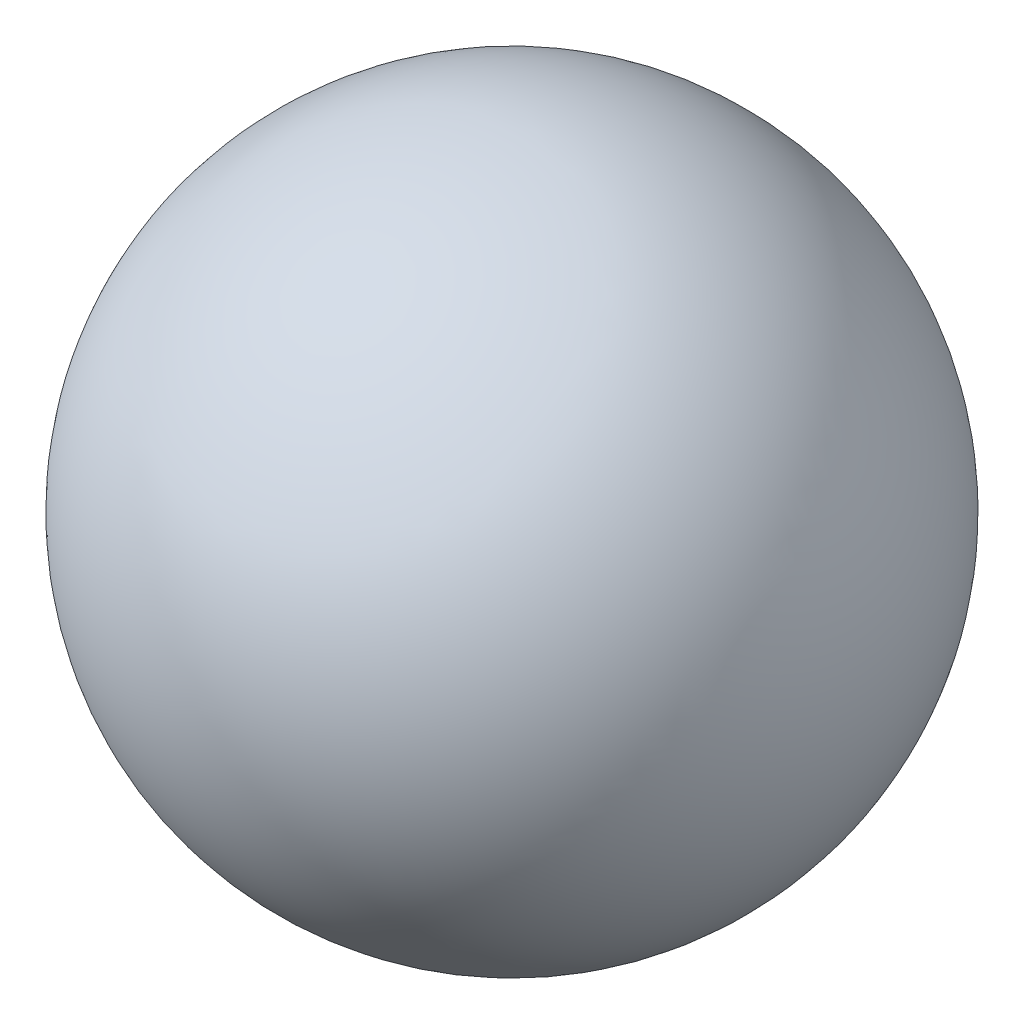
from build123d import *


with BuildPart() as part:
    # Эскиз3 → Revolve 135 (revolve)
    with BuildSketch(Plane.XY):
        with BuildLine():
            Line((-1000, 0), (1000, 0))
            ThreePointArc((1000, 0), (0, 1000), (-1000, 0))
        make_face()
    revolve(axis=Axis((-2000, 0, 0), (1, 0, 0)))


solid = part.part
